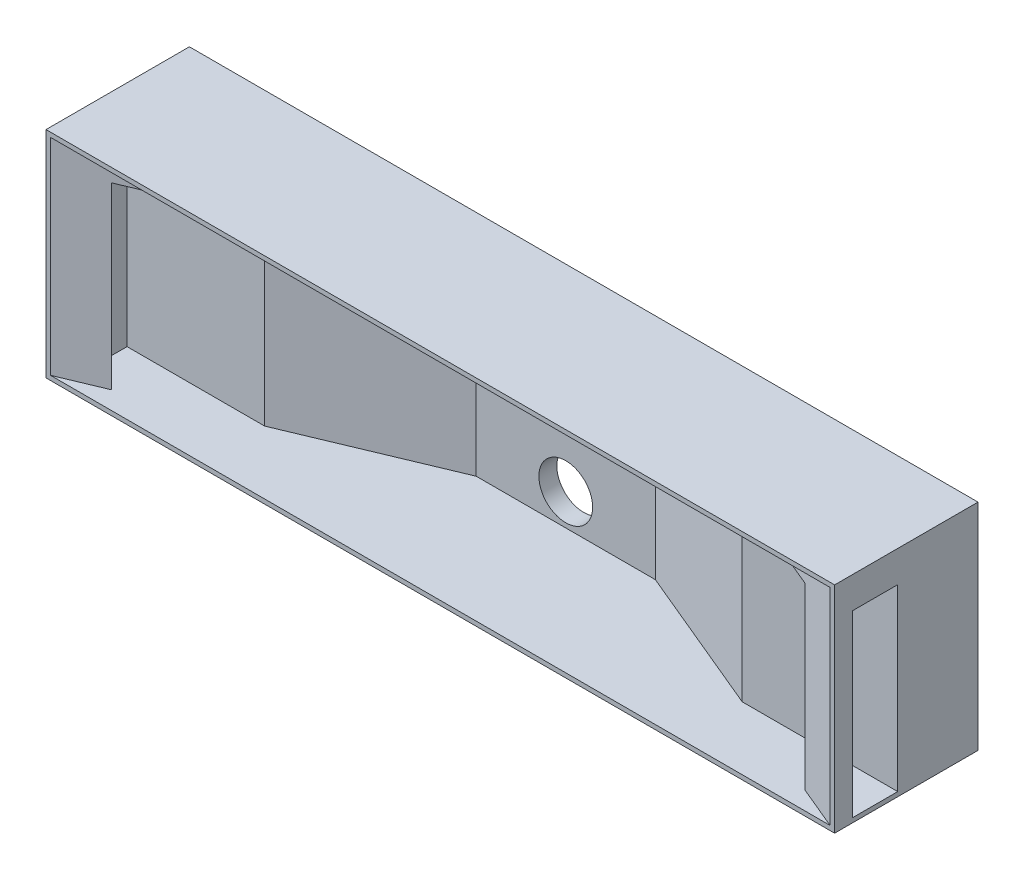
from build123d import *

# Parameters (mm, degrees)
SKETCH1_W            = 558.8
SKETCH1_H            = 152.4
SKETCH1_W_2          = 552.45
SKETCH1_H_2          = 146.05
BOSS_EXTRUDE2_DEPTH  = 101.6
BOSS_EXTRUDE3_REACH  = 151.225
SKETCH5_W            = 552.45
SKETCH5_H            = 146.05
BOSS_EXTRUDE15_DEPTH = 12.7
SKETCH8_R            = 19.05
CUT_EXTRUDE1_DEPTH   = 102.6
SKETCH9_W            = 32.035224234
SKETCH9_H            = 127
CUT_EXTRUDE2_DEPTH   = 546.1


with BuildPart() as part:
    # Sketch1 → Boss-Extrude2 (new body)
    with BuildSketch(Plane.XY):
        with Locations((279.4, 76.2)):
            Rectangle(SKETCH1_W, SKETCH1_H)
        with Locations((279.4, 76.2)):
            Rectangle(SKETCH1_W_2, SKETCH1_H_2, mode=Mode.SUBTRACT)
    extrude(amount=BOSS_EXTRUDE2_DEPTH)

    # Sketch2 → Boss-Extrude3 (add, up to next)
    with BuildSketch(Plane(origin=(0, 3.175, 0), x_dir=(1, 0, 0), z_dir=(0, 1, 0)), mode=Mode.PRIVATE) as boss_extrude3_sk1:
        Polygon((3.175, -101.6), (215.9, -12.7), (3.175, -12.7), align=None)
    boss_extrude3_tool1 = extrude(boss_extrude3_sk1.sketch, amount=BOSS_EXTRUDE3_REACH, mode=Mode.PRIVATE) - part.part
    add(boss_extrude3_tool1.solids().sort_by_distance((74.083333, 3.175, 42.333333))[0])
    # Sketch2 → Boss-Extrude3 (add, up to next)
    with BuildSketch(Plane(origin=(0, 3.175, 0), x_dir=(1, 0, 0), z_dir=(0, 1, 0)), mode=Mode.PRIVATE) as boss_extrude3_sk2:
        Polygon((342.9, -12.7), (555.625, -101.6), (555.625, -12.7), align=None)
    boss_extrude3_tool2 = extrude(boss_extrude3_sk2.sketch, amount=BOSS_EXTRUDE3_REACH, mode=Mode.PRIVATE) - part.part
    add(boss_extrude3_tool2.solids().sort_by_distance((484.716667, 3.175, 42.333333))[0])

    # Sketch5 → Boss-Extrude15 (add)
    with BuildSketch(Plane(origin=(0, 0, 12.7), x_dir=(-1, 0, 0), z_dir=(0, 0, -1))):
        with Locations((-279.4, 76.2)):
            Rectangle(SKETCH5_W, SKETCH5_H)
    extrude(amount=BOSS_EXTRUDE15_DEPTH)

    # Sketch8 → Cut-Extrude1 (cut, through all)
    with BuildSketch(Plane(origin=(0, 0, 0), x_dir=(-1, 0, 0), z_dir=(0, 0, -1))):
        with Locations((-279.4, 25.4)):
            Circle(SKETCH8_R)
    extrude(amount=-CUT_EXTRUDE1_DEPTH, mode=Mode.SUBTRACT)

    # Sketch9 → Cut-Extrude2 (cut)
    with BuildSketch(Plane(origin=(558.8, 0, 0), x_dir=(0, 0, -1), z_dir=(1, 0, 0))):
        with Locations((-72.882387883, 66.675)):
            Rectangle(SKETCH9_W, SKETCH9_H)
    extrude(amount=-CUT_EXTRUDE2_DEPTH, mode=Mode.SUBTRACT)


solid = part.part
